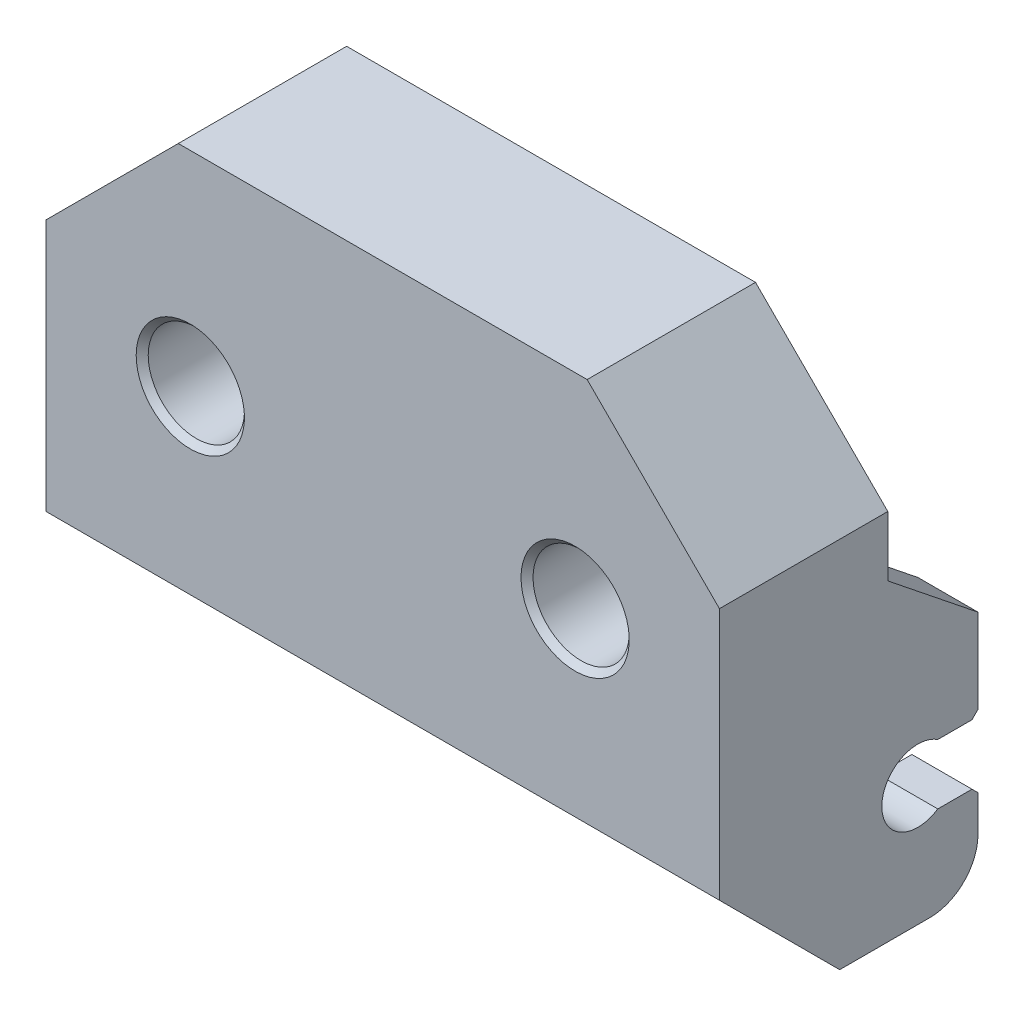
from build123d import *

# Parameters (mm, degrees)
BOSS_EXTRU_1_DEPTH      = 7
CHANFREIN2_SIZE         = 4
CHANFREIN3_SIZE         = 5.5
CHANFREIN4_SIZE         = 5
BOSS_EXTRU_2_DEPTH      = 1.5
ESQUISSE5_W             = 9
ESQUISSE5_H             = 1.25
BOSS_EXTRU_3_DEPTH      = 4
ENL_V_MAT_EXTRU_1_DEPTH = 1.25
ESQUISSE7_R             = 2.75
BOSS_EXTRU_4_DEPTH      = 5.5
ENL_V_START             = -2.5
ESQUISSE9_R             = 2
ENL_V_MAT_EXTRU_2_DEPTH = 4.5
ESQUISSE10_W            = 1.052895571
ESQUISSE10_H            = 1
ESQUISSE10_W_2          = 1
ESQUISSE10_H_2          = 3.75
ESQUISSE10_H_3          = 3.95048694
ESQUISSE10_W_3          = 1.193094599
BOSS_EXTRU_5_DEPTH      = 5.5
ESQUISSE11_W            = 2.5
ESQUISSE11_H            = 10
BOSS_EXTRU_6_DEPTH      = 3.75
ENL_V_MAT_EXTRU_3_DEPTH = 28
ESQUISSE13_W            = 2.5
ESQUISSE13_H            = 3.75
BOSS_EXTRU_7_DEPTH      = 3
ENL_V_MAT_EXTRU_4_DEPTH = 28
CONG_1_R                = 2
CHANFREIN7_SIZE         = 0.25
CHANFREIN8_SIZE         = 0.25


with BuildPart() as part:
    # Esquisse3 → Boss.-Extru.1 (new body)
    with BuildSketch(Plane.XY):
        Polygon((-5.371411117, 0), (17.628588883, 0), (17.628588883, -18.5), (20.128588883, -18.5), (20.128588883, 2.5), (-7.871411117, 2.5), (-7.871411117, -18.5), (-5.371411117, -18.5), align=None)
    extrude(amount=BOSS_EXTRU_1_DEPTH)

    # Chanfrein2
    chanfrein2_edges = [part.edges().sort_by_distance(p)[0] for p in [
        (17.628588883, 0, 3.5),
        (-5.371411117, 0, 3.5),
    ]]
    chamfer(chanfrein2_edges, length=CHANFREIN2_SIZE)

    # Chanfrein3
    chanfrein3_edges = [part.edges().sort_by_distance(p)[0] for p in [
        (-7.871411117, 2.5, 3.5),
        (20.128588883, 2.5, 3.5),
    ]]
    chamfer(chanfrein3_edges, length=CHANFREIN3_SIZE)

    # Chanfrein4
    chanfrein4_edges = [part.edges().sort_by_distance(p)[0] for p in [
        (18.878588883, -18.5, 7),
        (-6.621411117, -18.5, 7),
    ]]
    chamfer(chanfrein4_edges, length=CHANFREIN4_SIZE)

    # Esquisse4 → Boss.-Extru.2 (add)
    with BuildSketch(Plane.XY.offset(7)):
        Polygon((-5.371411117, -13.5), (17.628588883, -13.5), (17.628588883, -4), (13.628588883, 0), (-1.371411117, 0), (-5.371411117, -4), align=None)
    extrude(amount=-BOSS_EXTRU_2_DEPTH)

    # Esquisse5 → Boss.-Extru.3 (add)
    with BuildSketch(Plane(origin=(0, 0, 5.5), x_dir=(-1, 0, 0), z_dir=(0, 0, -1))):
        with Locations((-13.128588883, -12.875)):
            Rectangle(ESQUISSE5_W, ESQUISSE5_H)
        with Locations((0.871411117, -12.875)):
            Rectangle(ESQUISSE5_W, ESQUISSE5_H)
    extrude(amount=BOSS_EXTRU_3_DEPTH)

    # Esquisse6 → Enlèv. mat.-Extru.1 (cut)
    with BuildSketch(Plane.XZ.offset(13.5)):
        Polygon((17.628588883, 1.5), (8.628588883, 5.5), (8.628588883, 1.5), align=None)
        Polygon((-5.371411117, 1.5), (3.628588883, 5.5), (3.628588883, 1.5), align=None)
    extrude(amount=-ENL_V_MAT_EXTRU_1_DEPTH, mode=Mode.SUBTRACT)

    # Esquisse7 → Boss.-Extru.4 (add)
    with BuildSketch(Plane(origin=(0, 0, 5.5), x_dir=(-1, 0, 0), z_dir=(0, 0, -1))):
        with Locations((-14.128588883, -6)):
            Circle(ESQUISSE7_R)
        with Locations((1.871411117, -6)):
            Circle(ESQUISSE7_R)
    extrude(amount=BOSS_EXTRU_4_DEPTH)

    # Esquisse9 → Enlèv. mat.-Extru.2 (cut)
    with BuildSketch(Plane(origin=(0, 0, 0), x_dir=(-1, 0, 0), z_dir=(0, 0, -1)).offset(ENL_V_START)):
        with Locations((-14.128588883, -6)):
            Circle(ESQUISSE9_R)
        with Locations((1.871411117, -6)):
            Circle(ESQUISSE9_R)
    extrude(amount=-ENL_V_MAT_EXTRU_2_DEPTH, mode=Mode.SUBTRACT)

    # Esquisse10 → Boss.-Extru.5 (add)
    with BuildSketch(Plane(origin=(0, 0, 0), x_dir=(-1, 0, 0), z_dir=(0, 0, -1))):
        with Locations((-17.253588884, -6)):
            Rectangle(ESQUISSE10_W, ESQUISSE10_H)
        with Locations((-14.128588883, -1.875)):
            Rectangle(ESQUISSE10_W_2, ESQUISSE10_H_2)
        with Locations((1.871411117, -1.875)):
            Rectangle(ESQUISSE10_W_2, ESQUISSE10_H_3)
        with Locations((4.996411117, -6)):
            Rectangle(ESQUISSE10_W_3, ESQUISSE10_H)
    extrude(amount=-BOSS_EXTRU_5_DEPTH)

    # Esquisse11 → Boss.-Extru.6 (add)
    with BuildSketch(Plane(origin=(0, 0, 0), x_dir=(-1, 0, 0), z_dir=(0, 0, -1))):
        with Locations((6.621411117, -13.5)):
            Rectangle(ESQUISSE11_W, ESQUISSE11_H)
        with Locations((-18.878588883, -13.5)):
            Rectangle(ESQUISSE11_W, ESQUISSE11_H)
    extrude(amount=BOSS_EXTRU_6_DEPTH)

    # Esquisse12 → Enlèv. mat.-Extru.3 (cut)
    with BuildSketch(Plane(origin=(-5.371411117, 0, 0), x_dir=(0, 0, -1), z_dir=(1, 0, 0)).offset(ENL_V_START)):
        with BuildLine():
            Line((3.75, -14.75), (3.75, -12.25))
            Line((3.75, -12.25), (2.079156198, -12.25))
            ThreePointArc((2.079156198, -12.25), (-0.25, -13.5), (2.079156198, -14.75))
            Line((2.079156198, -14.75), (3.75, -14.75))
        make_face()
    extrude(amount=ENL_V_MAT_EXTRU_3_DEPTH, mode=Mode.SUBTRACT)

    # Esquisse13 → Boss.-Extru.7 (add)
    with BuildSketch(Plane(origin=(0, -8.5, 0), x_dir=(1, 0, 0), z_dir=(0, 1, 0))):
        with Locations((18.878588883, 1.875)):
            Rectangle(ESQUISSE13_W, ESQUISSE13_H)
        with Locations((-6.621411117, 1.875)):
            Rectangle(ESQUISSE13_W, ESQUISSE13_H)
    extrude(amount=BOSS_EXTRU_7_DEPTH)

    # Esquisse14 → Enlèv. mat.-Extru.4 (cut)
    with BuildSketch(Plane.ZY.offset(7.871411117)):
        Polygon((-3.75, -5.5), (-3.75, -8.5), (0, -5.5), align=None)
    extrude(amount=-ENL_V_MAT_EXTRU_4_DEPTH, mode=Mode.SUBTRACT)

    # Congé1
    cong_1_edges = [part.edges().sort_by_distance(p)[0] for p in [
        (-6.621411117, -18.5, -3.75),
        (18.878588883, -18.5, -3.75),
    ]]
    fillet(cong_1_edges, radius=CONG_1_R)

    # Chanfrein7
    chanfrein7_edges = [part.edges().sort_by_distance(p)[0] for p in [
        (18.878588883, -14.75, -3.75),
        (18.878588883, -12.25, -3.75),
        (-6.621411117, -12.25, -3.75),
        (-6.621411117, -14.75, -3.75),
    ]]
    chamfer(chanfrein7_edges, length=CHANFREIN7_SIZE)

    # Chanfrein8
    chanfrein8_edges = [part.edges().sort_by_distance(p)[0] for p in [
        (16.128588883, -6, 7),
        (0.128588883, -6, 7),
    ]]
    chamfer(chanfrein8_edges, length=CHANFREIN8_SIZE)


solid = part.part
